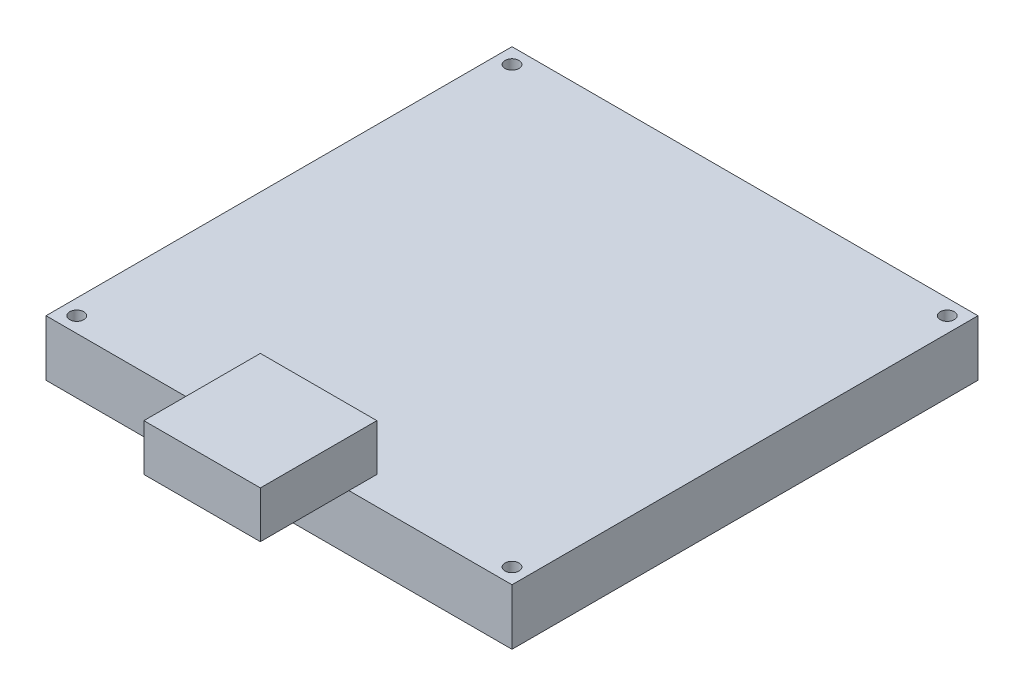
from build123d import *

# Parameters (mm, degrees)
SKETCH1_W           = 100
SKETCH1_H           = 100
SKETCH1_R           = 1.5
BOSS_EXTRUDE1_DEPTH = 12
SKETCH2_W           = 25
SKETCH2_H           = 25
BOSS_EXTRUDE2_DEPTH = 10


with BuildPart() as part:
    # Sketch1 → Boss-Extrude1 (new body)
    with BuildSketch(Plane(origin=(0, 0, 0), x_dir=(1, 0, 0), z_dir=(0, 1, 0))):
        with Locations((50, 50)):
            Rectangle(SKETCH1_W, SKETCH1_H)
        with Locations((96.7, 96.7)):
            Circle(SKETCH1_R, mode=Mode.SUBTRACT)
        with Locations((96.7, 3.3)):
            Circle(SKETCH1_R, mode=Mode.SUBTRACT)
        with Locations((3.3, 96.7)):
            Circle(SKETCH1_R, mode=Mode.SUBTRACT)
        with Locations((3.3, 3.3)):
            Circle(SKETCH1_R, mode=Mode.SUBTRACT)
    extrude(amount=BOSS_EXTRUDE1_DEPTH)

    # Sketch2 → Boss-Extrude2 (add)
    with BuildSketch(Plane(origin=(0, 12, 0), x_dir=(1, 0, 0), z_dir=(0, 1, 0))):
        with Locations((52.5, -6.5)):
            Rectangle(SKETCH2_W, SKETCH2_H)
    extrude(amount=BOSS_EXTRUDE2_DEPTH)


solid = part.part
